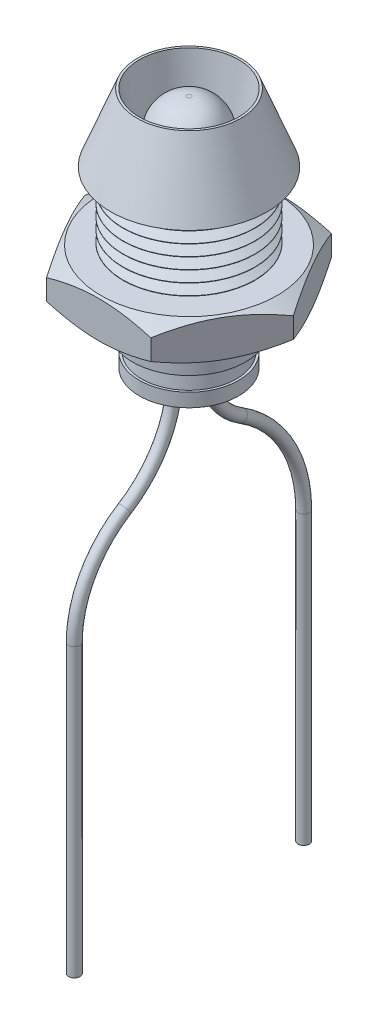
from build123d import *

# Parameters (mm, degrees)
LPATTERN1_COUNT       = 11
LPATTERN1_PITCH       = 0.5
SKETCH7_R             = 2.6
BOSS_EXTRUDE1_DEPTH   = 1.74
SKETCH12_R            = 1.5
CUT_EXTRUDE5_DEPTH    = 4.4
SKETCH13_W            = 0.8
SKETCH13_H            = 0.8
CUT_EXTRUDE6_DEPTH    = 0.6
SKETCH14_R            = 0.6
CUT_EXTRUDE7_DEPTH    = 0.1
CUT_EXTRUDE9_DEPTH    = 0.01
CUT_EXTRUDE8_DEPTH    = 1.2
SKETCH_WIRE_PROFILE_R = 0.25


with BuildPart() as part:
    # Sketch1 → Revolve1 (revolve)
    with BuildSketch(Plane.XY, mode=Mode.PRIVATE) as revolve1_sk:
        Polygon((0, 0), (0, 9.25), (2.3, 9.25), (3.47, 6.25), (2.92, 6.25), (2.92, 0.6), (2.5, 0.6), (2.5, 0), align=None)
    revolve(revolve1_sk.sketch.rotate(Axis((0, 0, 0), (0, 1, 0)), 90), axis=Axis((0, 0, 0), (0, 1, 0)))

    # Sketch6 → Cut-Revolve2 (revolve, cut)
    with BuildSketch(Plane.XY, mode=Mode.PRIVATE) as cut_revolve2_sk:
        Polygon((0, 0), (0, 9.25), (2.2, 9.25), (1.75, 5.8), (2.05, 5.8), (2.05, 0), align=None)
    revolve(cut_revolve2_sk.sketch.rotate(Axis((0, 0, 0), (0, 1, 0)), 90), axis=Axis((0, 0, 0), (0, 1, 0)), mode=Mode.SUBTRACT)

    # Sketch5 → Cut-Revolve1 (revolve, cut)
    with BuildSketch(Plane.XY, mode=Mode.PRIVATE) as cut_revolve1_sk:
        Polygon((3.433012702, 0.85), (3.433012702, 0.35), (2.933012702, 0.35), (2.5, 0.6), (2.933012702, 0.85), align=None)
    cut_revolve1 = revolve(cut_revolve1_sk.sketch.rotate(Axis((0, 0, 0), (0, 1, 0)), 90), axis=Axis((0, 0, 0), (0, 1, 0)), mode=Mode.SUBTRACT)

    # LPattern1: Cut-Revolve1 ×11
    with Locations(*[(0, i * LPATTERN1_PITCH, 0) for i in range(1, LPATTERN1_COUNT)]):
        add(cut_revolve1, mode=Mode.SUBTRACT)


with BuildPart() as body_2:
    # Sketch7 → Boss-Extrude1 (new body)
    with BuildSketch(Plane(origin=(0, 3.25, 0), x_dir=(-1, 0, 0), z_dir=(0, -1, 0))):
        Polygon((-4.618802154, 0), (-2.309401077, -4), (2.309401077, -4), (4.618802154, 0), (2.309401077, 4), (-2.309401077, 4), align=None)
        with Locations(Location((0, 0, 0), (0, 0, 90))):
            Circle(SKETCH7_R, mode=Mode.SUBTRACT)
    extrude(amount=BOSS_EXTRUDE1_DEPTH)

    # Sketch8 → Cut-Revolve3 (revolve, cut)
    with BuildSketch(Plane.XY):
        Polygon((3.9, 3.25), (4.618802154, 3.25), (4.618802154, 2.834999383), align=None)
        Polygon((3.9, 1.51), (4.618802154, 1.51), (4.618802154, 1.925000617), align=None)
    revolve(axis=Axis((0, 1.51, 0), (0, 1, 0)), mode=Mode.SUBTRACT)


with BuildPart() as body_3:
    # Sketch11 → Revolve2 (revolve)
    with BuildSketch(Plane.XY):
        Polygon((0, 3.55), (0, -1.45), (2.2, -1.45), (2.2, -0.85), (2.1, -0.85), (1.75, 3.55), align=None)
    revolve(axis=Axis((0, 3.55, 0), (0, 1, 0)))

    # Sketch12 → Cut-Extrude5 (cut)
    with BuildSketch(Plane(origin=(0, 3.55, 0), x_dir=(1, 0, 0), z_dir=(0, 1, 0))):
        with Locations(Location((0, 0, 0), (0, 0, 270))):
            Circle(SKETCH12_R)
    extrude(amount=-CUT_EXTRUDE5_DEPTH, mode=Mode.SUBTRACT)

    # Sketch13 → Cut-Extrude6 (cut)
    with BuildSketch(Plane(origin=(0, -0.85, 0), x_dir=(1, 0, 0), z_dir=(0, 1, 0))):
        with Locations((0, 0.635)):
            Rectangle(SKETCH13_W, SKETCH13_H)
        with Locations((0, -0.635)):
            Rectangle(SKETCH13_W, SKETCH13_H)
    extrude(amount=-CUT_EXTRUDE6_DEPTH, mode=Mode.SUBTRACT)

    # Sketch14 → Cut-Extrude7 (cut)
    with BuildSketch(Plane.XZ.offset(1.45)):
        with Locations(Location((0, -0.635, 0), (0, 0, 270))):
            Circle(SKETCH14_R)
        with Locations(Location((0, 0.635, 0), (0, 0, 270))):
            Circle(SKETCH14_R)
    extrude(amount=-CUT_EXTRUDE7_DEPTH, mode=Mode.SUBTRACT)

    # Sketch21 → Cut-Extrude9 (cut)
    with BuildSketch(Plane.XZ.offset(1.45)):
        with BuildLine():
            add(Edge.make_bspline(
                [(0.273529412, 1.447840074), (0.27443456, 1.445230513), (0.276121923, 1.440365812), (0.278035768, 1.43334284), (0.279568733, 1.427239635), (0.280613767, 1.421917716), (0.281006885, 1.417308737), (0.280424934, 1.413333645), (0.279237509, 1.409821505), (0.276884702, 1.407004648), (0.273720993, 1.404709032), (0.269519632, 1.403142455), (0.264462408, 1.401735067), (0.258336457, 1.400989887), (0.251149688, 1.400693153), (0.242836968, 1.400172754), (0.233225333, 1.400156908), (0.226424337, 1.400054606), (0.222794118, 1.4)],
                knots=[0, 0, 0, 0, 1.351975101, 2.52033068, 3.562719996, 4.432170766, 5.176088948, 5.812532786, 6.389296298, 6.965620705, 7.577732788, 8.283941723, 9.146375963, 10.145613058, 11.295182858, 12.669444765, 14.222224263, 16, 16, 16, 16], degree=3))
            add(Edge.make_bspline(
                [(0.222794118, 1.4), (0.219071741, 1.399991139), (0.212040265, 1.3999744), (0.202157335, 1.40008419), (0.193566561, 1.40041467), (0.184356194, 1.400667129), (0.175129, 1.401545216), (0.166256467, 1.402992745), (0.159889206, 1.405417702), (0.155552653, 1.408994174), (0.153077151, 1.413724361), (0.151883362, 1.41708111), (0.151240809, 1.418887868)],
                knots=[0, 0, 0, 0, 1.402041787, 2.648421349, 3.722147351, 4.640185661, 6.117966101, 7.211050041, 8.017924191, 8.656254393, 9.276733986, 10, 10, 10, 10], degree=3))
            Line((0.151240809, 1.418887868), (0.114568015, 1.532352941))
            Line((0.114568015, 1.532352941), (-0.111810662, 1.532352941))
            Line((-0.111810662, 1.532352941), (-0.146553309, 1.422058824))
            add(Edge.make_bspline(
                [(-0.146553309, 1.422058824), (-0.14718209, 1.420062783), (-0.148379473, 1.416261741), (-0.151098453, 1.411011595), (-0.155477715, 1.406871431), (-0.161652247, 1.403763027), (-0.170179438, 1.401897514), (-0.181343594, 1.400541082), (-0.195818647, 1.400232876), (-0.206573, 1.400083565), (-0.212591912, 1.4)],
                knots=[0, 0, 0, 0, 0.662368552, 1.261342941, 1.847645799, 2.537239812, 3.42265718, 4.595262896, 6.094463672, 8, 8, 8, 8], degree=3))
            add(Edge.make_bspline(
                [(-0.212591912, 1.4), (-0.215946842, 1.400034588), (-0.222290174, 1.400099986), (-0.231254194, 1.400364753), (-0.239067797, 1.400782935), (-0.245802724, 1.401249726), (-0.251450942, 1.402164085), (-0.256200805, 1.40355559), (-0.260040843, 1.405388188), (-0.2639932, 1.408619765), (-0.266614398, 1.414884138), (-0.266310121, 1.424096173), (-0.263399532, 1.435511994), (-0.260713286, 1.443997178), (-0.259191176, 1.448805147)],
                knots=[0, 0, 0, 0, 1.279822224, 2.419822313, 3.420424811, 4.264789446, 4.993926375, 5.598399463, 6.14718048, 6.607326483, 7.517039103, 8.604050794, 10.075749779, 12, 12, 12, 12], degree=3))
            Line((-0.259191176, 1.448805147), (-0.077757353, 1.976148897))
            add(Edge.make_bspline(
                [(-0.077757353, 1.976148897), (-0.076809363, 1.978519067), (-0.075056291, 1.982902113), (-0.071564085, 1.988885883), (-0.066325344, 1.993559462), (-0.058704747, 1.996445456), (-0.048741915, 1.998629038), (-0.038475692, 1.999296308), (-0.028585702, 1.999590145), (-0.019625036, 1.999908644), (-0.009513233, 2.00002738), (-0.002389723, 2.000009473), (0.001378676, 2)],
                knots=[0, 0, 0, 0, 0.856868194, 1.584566637, 2.305859304, 3.162727498, 4.285524966, 5.725550839, 6.605441018, 7.608682037, 8.734971556, 10, 10, 10, 10], degree=3))
            add(Edge.make_bspline(
                [(0.001378676, 2), (0.005698546, 2.00000908), (0.01392495, 2.000026371), (0.025553092, 1.99991118), (0.035800871, 1.999593381), (0.046975688, 1.999291156), (0.058430399, 1.998655512), (0.069548744, 1.996455839), (0.07792082, 1.993513589), (0.08375434, 1.988630178), (0.087547353, 1.982190213), (0.089244841, 1.977379318), (0.090165441, 1.974770221)],
                knots=[0, 0, 0, 0, 1.298203691, 2.47219252, 3.494555852, 4.378870695, 5.833194716, 6.932857721, 7.781737059, 8.467837287, 9.169060755, 10, 10, 10, 10], degree=3))
            Line((0.090165441, 1.974770221), (0.273529412, 1.447840074))
        make_face()
        Polygon((0, 1.887913603), (-0.081341912, 1.629411765), (0.083272059, 1.629411765), align=None, mode=Mode.SUBTRACT)
        with BuildLine():
            add(Edge.make_bspline(
                [(0.225, -1.900321691), (0.224995136, -1.903815648), (0.22498617, -1.910257369), (0.224392221, -1.91917817), (0.223645718, -1.926697431), (0.222420155, -1.933031797), (0.220733737, -1.938384793), (0.218602417, -1.94328823), (0.215175557, -1.948093056), (0.21170836, -1.952622138), (0.207846764, -1.956935105), (0.203447422, -1.960595969), (0.19796425, -1.964873148), (0.188648602, -1.971299141), (0.174703745, -1.97941559), (0.155456504, -1.988707835), (0.132897883, -1.996705559), (0.107558863, -2.003480153), (0.079476607, -2.00802286), (0.059898701, -2.008550539), (0.049770221, -2.008823529)],
                knots=[0, 0, 0, 0, 0.817477301, 1.507162764, 2.091525744, 2.585101367, 3.013698999, 3.403571139, 3.830139735, 4.389521305, 4.739690108, 5.181838318, 5.726127005, 6.367582384, 7.828489835, 9.497787956, 11.362220851, 13.420571043, 15.630867283, 18, 18, 18, 18], degree=3))
            add(Edge.make_bspline(
                [(0.049770221, -2.008823529), (0.039788008, -2.008573868), (0.020313891, -2.008086809), (-0.00821827, -2.004610739), (-0.035233703, -1.998730883), (-0.060739548, -1.99044156), (-0.084628906, -1.979864196), (-0.106613945, -1.966638174), (-0.126923742, -1.951308547), (-0.145214609, -1.933496221), (-0.161639823, -1.913384242), (-0.175764876, -1.890732142), (-0.188134493, -1.865924079), (-0.198258849, -1.838733504), (-0.206503318, -1.809295444), (-0.211882781, -1.777450335), (-0.215693082, -1.743428356), (-0.21601206, -1.719956501), (-0.216176471, -1.707858456)],
                knots=[0, 0, 0, 0, 1.04884528, 2.046173269, 3.015214692, 3.949843553, 4.859908047, 5.754373417, 6.640074381, 7.528023805, 8.430832778, 9.361986752, 10.3273752, 11.339120453, 12.406480085, 13.534714217, 14.729323304, 16, 16, 16, 16], degree=3))
            add(Edge.make_bspline(
                [(-0.216176471, -1.707858456), (-0.215966482, -1.695485071), (-0.215557899, -1.671409759), (-0.21157719, -1.636377587), (-0.205344767, -1.603473889), (-0.196518888, -1.572735257), (-0.185343597, -1.544276025), (-0.172109442, -1.518056514), (-0.156779465, -1.494249307), (-0.139449472, -1.472784467), (-0.120038289, -1.453917326), (-0.098987849, -1.437155887), (-0.075946437, -1.423063782), (-0.051180131, -1.411505454), (-0.024902192, -1.402346497), (0.002794722, -1.395986605), (0.031764162, -1.39177157), (0.051547183, -1.391377337), (0.061626838, -1.391176471)],
                knots=[0, 0, 0, 0, 1.247364886, 2.427039795, 3.55045214, 4.621200906, 5.64704897, 6.629476075, 7.578181143, 8.497404382, 9.405200954, 10.302706402, 11.205651615, 12.122019826, 13.054178336, 14.006318378, 14.984198529, 16, 16, 16, 16], degree=3))
            add(Edge.make_bspline(
                [(0.061626838, -1.391176471), (0.069818067, -1.391387915), (0.085941251, -1.39180411), (0.109503778, -1.395091899), (0.131649781, -1.400005274), (0.152177086, -1.406262623), (0.170929754, -1.413415842), (0.185002438, -1.420566999), (0.194931233, -1.426386474), (0.201131342, -1.430274642), (0.206050596, -1.434038832), (0.210675724, -1.438363228), (0.214899001, -1.44296895), (0.21861567, -1.448108892), (0.220846046, -1.453549339), (0.222385309, -1.459682267), (0.223653751, -1.467009717), (0.224387109, -1.475631697), (0.224993234, -1.485928971), (0.224997602, -1.493381039), (0.225, -1.497472426)],
                knots=[0, 0, 0, 0, 1.99247574, 3.921884623, 5.777623321, 7.507428254, 9.139636718, 10.654923546, 11.341526285, 11.940176233, 12.43448366, 12.845959356, 13.479321404, 13.953882042, 14.379694984, 14.900487377, 15.490617055, 16.187164526, 17.004703962, 18, 18, 18, 18], degree=3))
            add(Edge.make_bspline(
                [(0.225, -1.497472426), (0.224941668, -1.501884812), (0.224834035, -1.510026425), (0.224214008, -1.521220236), (0.223058471, -1.530418898), (0.221278583, -1.537734909), (0.218580263, -1.543180149), (0.215562237, -1.547091845), (0.211923585, -1.549623975), (0.209224966, -1.549876452), (0.207904412, -1.55)],
                knots=[0, 0, 0, 0, 1.773747753, 3.272870731, 4.503340964, 5.498117188, 6.282928042, 6.926292104, 7.474587188, 8, 8, 8, 8], degree=3))
            add(Edge.make_bspline(
                [(0.207904412, -1.55), (0.20665162, -1.54986881), (0.203932223, -1.549584039), (0.199764337, -1.547902572), (0.195129822, -1.545374656), (0.188068005, -1.540132217), (0.177475084, -1.532395905), (0.162171835, -1.522897326), (0.143788667, -1.513166047), (0.126095152, -1.506208272), (0.110254623, -1.501486088), (0.096877237, -1.498859593), (0.082386184, -1.497389526), (0.072337924, -1.497171549), (0.067141544, -1.497058824)],
                knots=[0, 0, 0, 0, 0.294660949, 0.639611878, 1.045415135, 1.533607636, 2.701972583, 4.127801724, 5.759893443, 7.582166846, 8.583129585, 9.639604504, 10.779339718, 12, 12, 12, 12], degree=3))
            add(Edge.make_bspline(
                [(0.067141544, -1.497058824), (0.061337189, -1.49717886), (0.050025723, -1.497412785), (0.033588095, -1.500372044), (0.018013714, -1.504655431), (0.003491283, -1.511068303), (-0.009923339, -1.519173893), (-0.02249926, -1.528587257), (-0.033945952, -1.539683379), (-0.044334746, -1.552317889), (-0.053535957, -1.566391577), (-0.061587638, -1.58187121), (-0.068466513, -1.598712563), (-0.074077959, -1.616947143), (-0.078462307, -1.636447446), (-0.081646194, -1.657171949), (-0.083370895, -1.679106702), (-0.083670346, -1.694114862), (-0.083823529, -1.701792279)],
                knots=[0, 0, 0, 0, 0.972080817, 1.89438068, 2.79201181, 3.675405302, 4.546341706, 5.415605955, 6.303960111, 7.212703157, 8.153143135, 9.118265211, 10.13431466, 11.199471373, 12.313676298, 13.483115176, 14.712488772, 16, 16, 16, 16], degree=3))
            add(Edge.make_bspline(
                [(-0.083823529, -1.701792279), (-0.083705977, -1.710161577), (-0.083478881, -1.726329974), (-0.081325322, -1.749712579), (-0.07815529, -1.771395842), (-0.073425576, -1.791343825), (-0.067590688, -1.809609855), (-0.060327888, -1.826137264), (-0.052145688, -1.841088504), (-0.042696643, -1.854321074), (-0.032128282, -1.865880846), (-0.020486437, -1.875852495), (-0.007851245, -1.884314013), (0.005761394, -1.891314063), (0.020445077, -1.896489362), (0.036024811, -1.900171144), (0.052449025, -1.902641255), (0.063731541, -1.902839882), (0.069485294, -1.902941176)],
                knots=[0, 0, 0, 0, 1.39820726, 2.701155002, 3.920851914, 5.057115416, 6.123247462, 7.120555937, 8.069346848, 8.966541661, 9.830790757, 10.680415293, 11.521739042, 12.366630257, 13.231390995, 14.116141633, 15.039287353, 16, 16, 16, 16], degree=3))
            add(Edge.make_bspline(
                [(0.069485294, -1.902941176), (0.074682154, -1.902832004), (0.084685634, -1.902621857), (0.099169907, -1.901109621), (0.112514891, -1.898551471), (0.128420543, -1.893756951), (0.146011652, -1.886570779), (0.164362551, -1.876843715), (0.179555623, -1.867354715), (0.190283346, -1.859903918), (0.197328922, -1.854610816), (0.201908694, -1.85217253), (0.20581119, -1.8504393), (0.208305596, -1.850135737), (0.209420956, -1.85)],
                knots=[0, 0, 0, 0, 1.227460679, 2.362749415, 3.435761231, 4.43188492, 6.282452832, 7.914022885, 9.332840532, 10.51031958, 11.001231841, 11.409295861, 11.73586979, 12, 12, 12, 12], degree=3))
            add(Edge.make_bspline(
                [(0.209420956, -1.85), (0.210810631, -1.850049547), (0.213356303, -1.85014031), (0.216977534, -1.851597582), (0.219634998, -1.854819394), (0.221594566, -1.859591572), (0.22322218, -1.866229939), (0.224198258, -1.875160024), (0.224863965, -1.886754289), (0.224951142, -1.895448866), (0.225, -1.900321691)],
                knots=[0, 0, 0, 0, 0.574868731, 1.05307148, 1.566117152, 2.257286433, 3.182192672, 4.393071976, 5.978517896, 8, 8, 8, 8], degree=3))
        make_face()
    extrude(amount=-CUT_EXTRUDE9_DEPTH, mode=Mode.SUBTRACT)


with BuildPart() as body_4:
    # Sketch15 → Revolve3 (revolve)
    with BuildSketch(Plane.XY):
        with BuildLine():
            Line((0, 3.55), (0, 8.95))
            Line((0, 8.95), (0.1, 8.95))
            ThreePointArc((0.1, 8.95), (1.012597494, 8.601904883), (1.461550875, 7.734468858))
            ThreePointArc((1.461550875, 7.734468858), (1.465567355, 7.690517591), (1.467640632, 7.646431907))
            ThreePointArc((1.467640632, 7.646431907), (1.491909844, 6.348316774), (1.5, 5.05))
            Line((1.5, 5.05), (1.5, 4.75))
            Line((1.5, 4.75), (1.89, 4.75))
            Line((1.89, 4.75), (1.89, 3.55))
            Line((1.89, 3.55), (0, 3.55))
        make_face()
    revolve(axis=Axis((0, 3.55, 0), (0, 1, 0)))

    # Sketch17 → Cut-Extrude8 (cut)
    with BuildSketch(Plane(origin=(0, 4.75, 0), x_dir=(1, 0, 0), z_dir=(0, 1, 0))):
        with BuildLine():
            Line((-1.109594521, 1.53), (1.109594521, 1.53))
            ThreePointArc((1.109594521, 1.53), (0, 1.89), (-1.109594521, 1.53))
        make_face()
    extrude(amount=-CUT_EXTRUDE8_DEPTH, mode=Mode.SUBTRACT)


with BuildPart() as body_5:
    # ADJUST LED WIRES: sweep along a path in Sketch Wire Path
    with BuildLine(Plane(origin=(0, 0, 0), x_dir=(0, 0, -1), z_dir=(1, 0, 0))) as adjust_led_wires_path:
        Line((-5.08, -22.158641443), (-5.08, -9.45))
        ThreePointArc((-5.08, -9.45), (-4.487058684, -7.162014737), (-2.8575, -5.45))
        ThreePointArc((-2.8575, -5.45), (-1.227941316, -3.737985263), (-0.635, -1.45))
        Line((-0.635, -1.45), (-0.635, 4.15))
        Line((-0.635, 4.15), (0, 4.15))
        Line((0, 4.15), (0.635, 4.15))
        Line((0.635, 4.15), (0.635, -1.45))
        ThreePointArc((0.635, -1.45), (1.079705987, -3.165988947), (2.301875, -4.45))
        ThreePointArc((2.301875, -4.45), (4.338823355, -6.590018422), (5.08, -9.45))
        Line((5.08, -9.45), (5.08, -22.158641443))
    # Sketch Wire Profile → ADJUST LED WIRES (sweep)
    with BuildSketch(Plane.XY):
        with Locations((0, 4.15)):
            Circle(SKETCH_WIRE_PROFILE_R)
    sweep(path=adjust_led_wires_path.line, transition=Transition.RIGHT)


solid = Compound([part.part, body_2.part, body_3.part, body_4.part, body_5.part])
